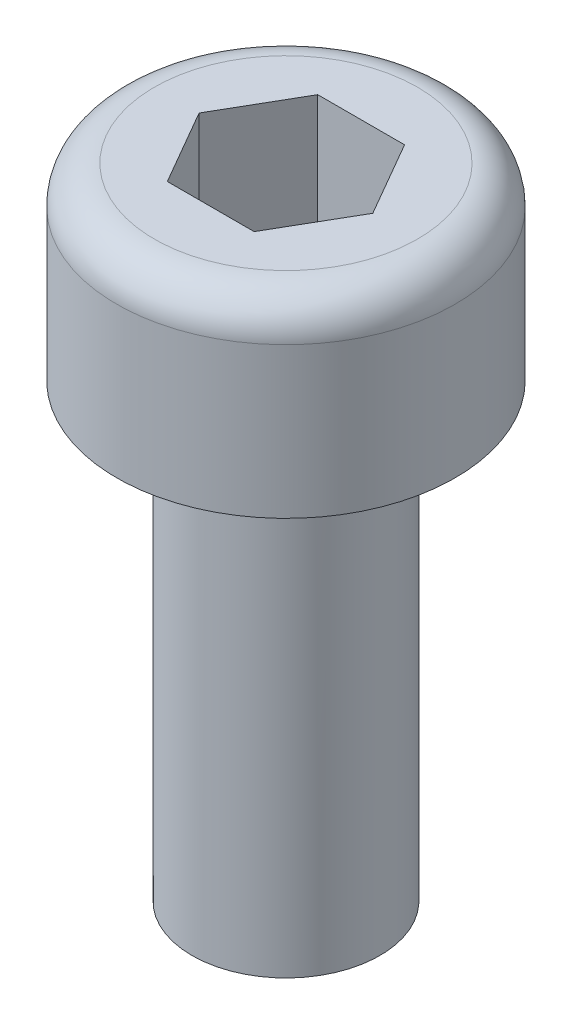
from build123d import *

# Parameters (mm, degrees)
CUT_EXTRUDE1_DEPTH = 2


with BuildPart() as part:
    # Sketch1 → Base-Revolve (revolve)
    with BuildSketch(Plane.XY, mode=Mode.PRIVATE) as base_revolve_sk:
        with BuildLine():
            Line((0, -6.334936491), (0, 2.5))
            Line((0, 2.5), (1.75, 2.5))
            ThreePointArc((1.75, 2.5), (2.103553391, 2.353553391), (2.25, 2))
            Line((2.25, 2), (2.25, 0))
            Line((2.25, 0), (1.25, 0))
            Line((1.25, 0), (1.25, -6))
            Line((1.25, -6), (0, -6.334936491))
        make_face()
    revolve(base_revolve_sk.sketch.rotate(Axis((0, 2.5, 0), (0, 1, 0)), 90), axis=Axis((0, 2.5, 0), (0, 1, 0)))  # turned: the seam where the file's is

    # Sketch2 → Cut-Extrude1 (cut)
    with BuildSketch(Plane(origin=(0, 2.5, 0), x_dir=(-1, 0, 0), z_dir=(0, 1, 0))):
        Polygon((-1.154700538, 0), (-0.577350269, -1), (0.577350269, -1), (1.154700538, 0), (0.577350269, 1), (-0.577350269, 1), align=None)
    extrude(amount=-CUT_EXTRUDE1_DEPTH, mode=Mode.SUBTRACT)


solid = part.part
